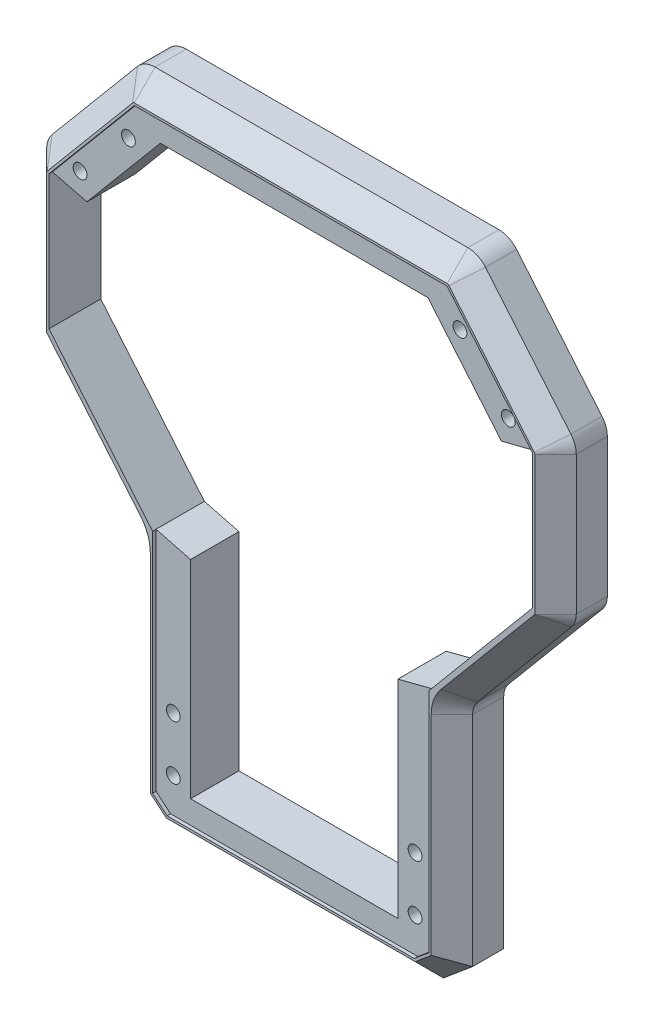
from build123d import *

# Parameters (mm, degrees)
RESSALTO_EXTRUS_O1_DEPTH = 22.5
CHANFRO1_SIZE            = 9
CORTE_EXTRUS_O1_REACH    = 24.5
ESBO_O3_W                = 1139.230904301
ESBO_O3_H                = 709.798033895
CORTE_EXTRUS_O5_DEPTH    = 1.5
ESBO_O5_R                = 3
CORTE_EXTRUS_O6_DEPTH    = 22
CORTE_EXTRUS_O8_DEPTH    = 10
CORTE_EXTRUS_O9_DEPTH    = 22


with BuildPart() as part:
    # Esboço1 → Ressalto-extrusão1 (new body, symmetric)
    with BuildSketch(Plane.XY):
        with BuildLine():
            Line((-57.319579452, 11.917784657), (57.319579452, 11.917784657))
            Line((57.319579452, 11.917784657), (70, 22.557920862))
            Line((70, 22.557920862), (70, 117.296691049))
            ThreePointArc((70, 117.296691049), (70.546863139, 120.39810603), (72.121492792, 123.125444592))
            Line((72.121492792, 123.125444592), (112.878507208, 171.697762944))
            ThreePointArc((112.878507208, 171.697762944), (114.453136861, 174.425101506), (115, 177.526516487))
            Line((115, 177.526516487), (115, 237.712528581))
            ThreePointArc((115, 237.712528581), (114.396926208, 241.132730014), (112.660444431, 244.140404678))
            Line((112.660444431, 244.140404678), (75.567830361, 288.345660754))
            ThreePointArc((75.567830361, 288.345660754), (72.133568548, 290.980862527), (67.90738593, 291.917784657))
            Line((67.90738593, 291.917784657), (-67.90738593, 291.917784657))
            ThreePointArc((-67.90738593, 291.917784657), (-72.133568548, 290.980862527), (-75.567830361, 288.345660754))
            Line((-75.567830361, 288.345660754), (-112.660444431, 244.140404678))
            ThreePointArc((-112.660444431, 244.140404678), (-114.396926208, 241.132730014), (-115, 237.712528581))
            Line((-115, 237.712528581), (-115, 177.526516487))
            ThreePointArc((-115, 177.526516487), (-114.453136861, 174.425101506), (-112.878507208, 171.697762944))
            Line((-112.878507208, 171.697762944), (-72.121492792, 123.125444592))
            ThreePointArc((-72.121492792, 123.125444592), (-70.546863139, 120.39810603), (-70, 117.296691049))
            Line((-70, 117.296691049), (-70, 22.557920862))
            Line((-70, 22.557920862), (-57.319579452, 11.917784657))
        make_face()
        Polygon((-90, 175.546696324), (-90, 233.938676426), (-58.131744291, 271.917784657), (58.131744291, 271.917784657), (90, 233.938676426), (90, 175.546696324), (45, 121.917784657), (45, 31.917784657), (-45, 31.917784657), (-45, 121.917784657), align=None, mode=Mode.SUBTRACT)
    extrude(amount=RESSALTO_EXTRUS_O1_DEPTH, both=True)

    # Chanfro1
    chanfro1_edges = [part.edges().sort_by_distance(p)[0] for p in [
        (70, 69.927305955, 22.5),
        (70.546863139, 120.39810603, 22.5),
        (92.5, 147.411603768, 22.5),
        (114.453136861, 174.425101506, 22.5),
        (115, 207.619522534, 22.5),
        (114.396926208, 241.132730014, 22.5),
        (94.114137396, 266.243032716, 22.5),
        (72.133568548, 290.980862527, 22.5),
        (0, 291.917784657, 22.5),
        (-72.133568548, 290.980862527, 22.5),
        (-94.114137396, 266.243032716, 22.5),
        (-114.396926208, 241.132730014, 22.5),
        (-115, 207.619522534, 22.5),
        (-114.453136861, 174.425101506, 22.5),
        (-92.5, 147.411603768, 22.5),
        (-70.546863139, 120.39810603, 22.5),
        (-70, 69.927305955, 22.5),
        (-63.659789726, 17.23785276, 22.5),
        (0, 11.917784657, 22.5),
        (63.659789726, 17.23785276, 22.5),
    ]]
    chamfer(chanfro1_edges, length=CHANFRO1_SIZE)

    # Esboço3 → Corte-extrusão1 (cut, up to next)
    with BuildSketch(Plane.XY, mode=Mode.PRIVATE) as corte_extrus_o1_sk1:
        with Locations((-153.157436203, 152.53565808)):
            Rectangle(ESBO_O3_W, ESBO_O3_H)
    corte_extrus_o1_tool1 = extrude(corte_extrus_o1_sk1.sketch, amount=-CORTE_EXTRUS_O1_REACH, mode=Mode.PRIVATE) & part.part
    add(corte_extrus_o1_tool1.solids().sort_by_distance((-153.157436, 152.535658, 0))[0], mode=Mode.SUBTRACT)

    # Esboço4 → Corte-extrusão5 (cut)
    with BuildSketch(Plane.XY.offset(22.5)):
        Polygon((-60, 27.220997444), (-53.679877109, 21.917784657), (53.679877109, 21.917784657), (60, 27.220997444), (60, 125.792574104), (105, 179.421485771), (105, 237.712528581), (67.90738593, 281.917784657), (-67.90738593, 281.917784657), (-105, 237.712528581), (-105, 179.421485771), (-60, 125.792574104), align=None)
        Polygon((-90, 175.546696324), (-90, 233.938676426), (-58.131744291, 271.917784657), (58.131744291, 271.917784657), (90, 233.938676426), (90, 175.546696324), (45, 121.917784657), (45, 31.917784657), (-45, 31.917784657), (-45, 121.917784657), align=None, mode=Mode.SUBTRACT)
    extrude(amount=-CORTE_EXTRUS_O5_DEPTH, mode=Mode.SUBTRACT)

    # Esboço5 → Corte-extrusão6 (cut, through all)
    with BuildSketch(Plane.XY.offset(21)):
        with Locations((-93, 244)):
            Circle(ESBO_O5_R)
        with Locations((-52.5, 60.396230411)):
            Circle(ESBO_O5_R)
        with Locations((-72, 266.917784657)):
            Circle(ESBO_O5_R)
        with Locations((-52.5, 36.917784657)):
            Circle(ESBO_O5_R)
        with Locations((52.5, 36.917784657)):
            Circle(ESBO_O5_R)
        with Locations((72, 266.917784657)):
            Circle(ESBO_O5_R)
        with Locations((52.5, 60.396230411)):
            Circle(ESBO_O5_R)
        with Locations((93, 244)):
            Circle(ESBO_O5_R)
    extrude(amount=-CORTE_EXTRUS_O6_DEPTH, mode=Mode.SUBTRACT)

    # Esboço7 → Corte-extrusão8 (cut)
    with BuildSketch(Plane(origin=(0, 0, 0), x_dir=(-1, 0, 0), z_dir=(0, 0, -1))):
        Polygon((-73.109400392, 271.401372964), (-76.43760157, 268.198809887), (-75.328201177, 263.715221581), (-70.890599608, 262.434196351), (-67.56239843, 265.636759427), (-68.671798823, 270.120347733), align=None)
        Polygon((-92.305785489, 247.981381613), (-96.100870363, 246.591898209), (-96.795084874, 242.610516596), (-93.694214511, 240.018618387), (-89.899129637, 241.408101791), (-89.204915126, 245.389483404), align=None)
        Polygon((93, 248.041451884), (89.5, 246.020725942), (89.5, 241.979274058), (93, 239.958548116), (96.5, 241.979274058), (96.5, 246.020725942), align=None)
        Polygon((72.832050294, 270.280475887), (69.503849117, 269.319706964), (68.671798823, 265.957015734), (71.167949706, 263.555093427), (74.496150883, 264.51586235), (75.328201177, 267.87855358), align=None)
        Polygon((-52.5, 64.437682295), (-56, 62.416956353), (-56, 58.375504468), (-52.5, 56.354778526), (-49, 58.375504468), (-49, 62.416956353), align=None)
        Polygon((52.5, 64.437682295), (49, 62.416956353), (49, 58.375504468), (52.5, 56.354778526), (56, 58.375504468), (56, 62.416956353), align=None)
        Polygon((52.5, 40.959236541), (49, 38.938510599), (49, 34.897058715), (52.5, 32.876332773), (56, 34.897058715), (56, 38.938510599), align=None)
        Polygon((-51.54604516, 40.845036049), (-55.424122052, 39.707559479), (-56.378076893, 35.780308087), (-53.45395484, 32.990533265), (-49.575877948, 34.128009835), (-48.621923107, 38.055261227), align=None)
    extrude(amount=-CORTE_EXTRUS_O8_DEPTH, mode=Mode.SUBTRACT)

    # Esboço8 → Corte-extrusão9 (cut, through all)
    with BuildSketch(Plane.XY.offset(21)):
        Polygon((-105, 237.712528581), (-90, 233.938676426), (-90, 175.546696324), (-45, 121.917784657), (-60, 125.792574104), (-105, 179.421485771), align=None)
        Polygon((90, 233.938676426), (105, 237.712528581), (105, 179.421485771), (60, 125.792574104), (45, 121.917784657), (90, 175.546696324), align=None)
    extrude(amount=-CORTE_EXTRUS_O9_DEPTH, mode=Mode.SUBTRACT)


solid = part.part
